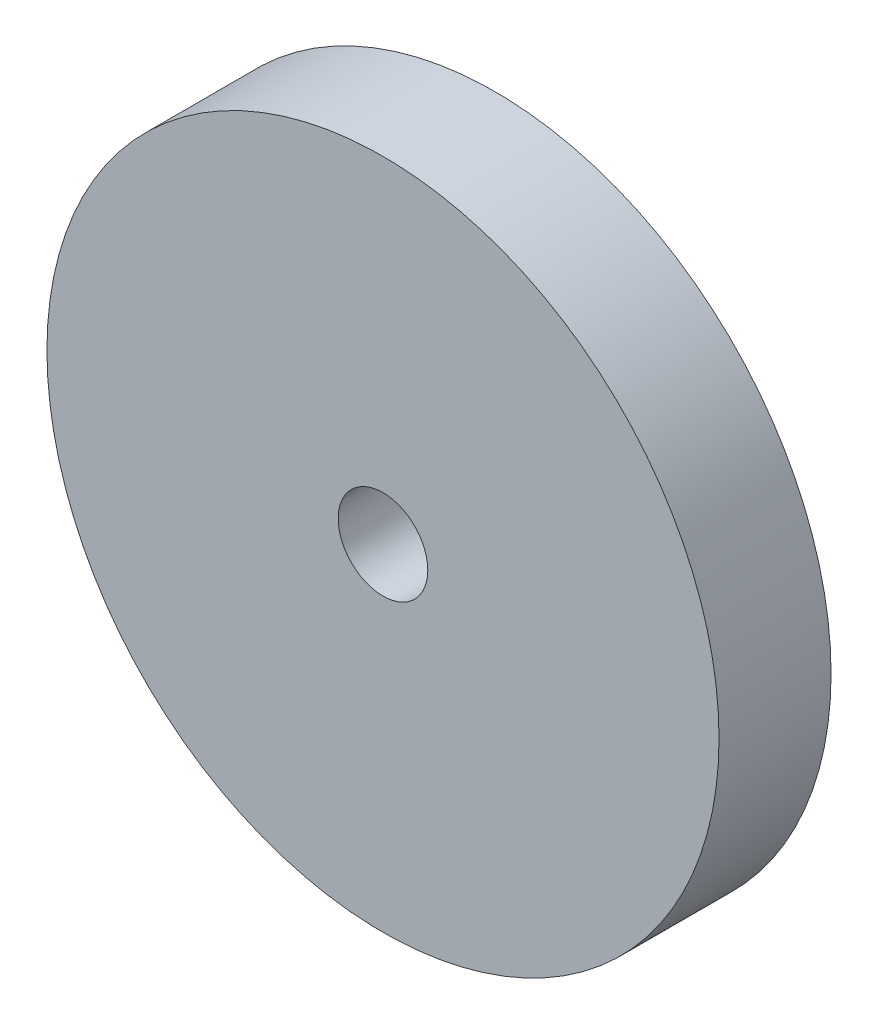
from build123d import *

# Parameters (mm, degrees)
SKETCH1_R           = 150
SKETCH1_R_2         = 20
BOSS_EXTRUDE1_DEPTH = 50


with BuildPart() as part:
    # Sketch1 → Boss-Extrude1 (new body)
    with BuildSketch(Plane.XY):
        Circle(SKETCH1_R)
        Circle(SKETCH1_R_2, mode=Mode.SUBTRACT)
    extrude(amount=BOSS_EXTRUDE1_DEPTH)


solid = part.part
